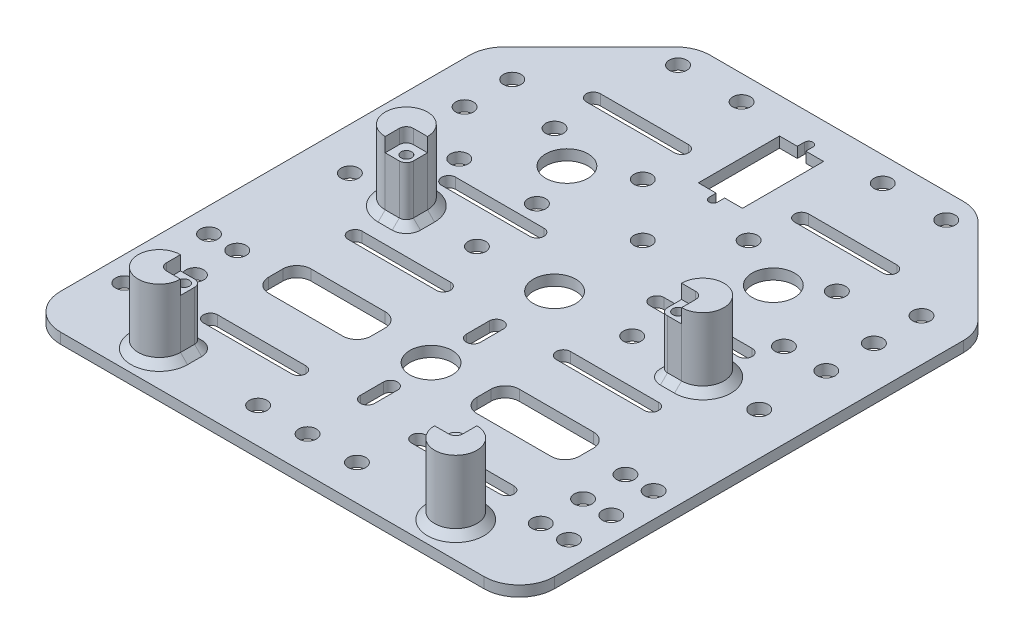
from build123d import *

# Parameters (mm, degrees)
SKETCH_1_W           = 140
SKETCH_1_H           = 160
EXTRUDE_1_DEPTH      = 4
SKETCH_2_R           = 2.5
SKETCH_2_R_2         = 6
CUT_EXTRUDE_1_DEPTH  = 213.64054176
EXTRUDE_3_DEPTH      = 20
CUT_EXTRUDE_START    = 20
SKETCH_4_4_W         = 84
SKETCH_4_4_H         = 70
CUT_EXTRUDE_2_DEPTH  = 4
FILLET_2_R           = 2
SKETCH_8_R           = 1.5
CUT_EXTRUDE_4_DEPTH  = 4
FILLET_3_R           = 2
CHAMFER_5_SIZE       = 2
SKETCH_1_2_W         = 140
SKETCH_1_2_H         = 160
CUT_EXTRUDE_6_DEPTH  = 1
CHAMFER_6_SIZE       = 30
SKETCH_5_W           = 12.5
SKETCH_5_H           = 23
CUT_EXTRUDE_8_DEPTH  = 214.541565041
SKETCH_14_R          = 2.5
CUT_EXTRUDE_9_DEPTH  = 214.541565041
FILLET_4_R           = 4
FILLET_5_R           = 10
CUT_EXTRUDE_10_DEPTH = 214.541565041


with BuildPart() as part:
    # Sketch 1 → Extrude 1 (new body)
    with BuildSketch(Plane(origin=(0, 0, 0), x_dir=(1, 0, 0), z_dir=(0, 1, 0))):
        with Locations((70, 80)):
            Rectangle(SKETCH_1_W, SKETCH_1_H)
    extrude(amount=EXTRUDE_1_DEPTH)

    # Sketch 2 → Cut-Extrude 1 (cut, through all)
    with BuildSketch(Plane(origin=(0, 4, 0), x_dir=(1, 0, 0), z_dir=(0, 1, 0))):
        with Locations(Location((55, 120, 0), (0, 0, 270))):
            Circle(SKETCH_2_R)
        with Locations(Location((85, 120, 0), (0, 0, 270))):
            Circle(SKETCH_2_R)
        with Locations(Location((12, 112.5, 0), (0, 0, 270))):
            Circle(SKETCH_2_R)
        with Locations(Location((128, 112.5, 0), (0, 0, 270))):
            Circle(SKETCH_2_R)
        with Locations(Location((12, 80, 0), (0, 0, 270))):
            Circle(SKETCH_2_R)
        with Locations(Location((128, 80, 0), (0, 0, 270))):
            Circle(SKETCH_2_R)
        with Locations(Location((7, 45.08040742, 0), (0, 0, 270))):
            Circle(SKETCH_2_R)
        with Locations(Location((15, 45.08040742, 0), (0, 0, 270))):
            Circle(SKETCH_2_R)
        with Locations(Location((15, 33.08040742, 0), (0, 0, 270))):
            Circle(SKETCH_2_R)
        with Locations(Location((15, 21.08040742, 0), (0, 0, 270))):
            Circle(SKETCH_2_R)
        with Locations(Location((7, 33.08040742, 0), (0, 0, 270))):
            Circle(SKETCH_2_R)
        with Locations(Location((7, 21.08040742, 0), (0, 0, 270))):
            Circle(SKETCH_2_R)
        with Locations(Location((133, 21.08040742, 0), (0, 0, 90))):
            Circle(SKETCH_2_R)
        with Locations(Location((133, 33.08040742, 0), (0, 0, 90))):
            Circle(SKETCH_2_R)
        with Locations(Location((125, 21.08040742, 0), (0, 0, 90))):
            Circle(SKETCH_2_R)
        with Locations(Location((125, 33.08040742, 0), (0, 0, 90))):
            Circle(SKETCH_2_R)
        with Locations(Location((125, 45.08040742, 0), (0, 0, 90))):
            Circle(SKETCH_2_R)
        with Locations(Location((133, 45.08040742, 0), (0, 0, 90))):
            Circle(SKETCH_2_R)
        with Locations(Location((70, 45, 0), (0, 0, 270))):
            Circle(SKETCH_2_R_2)
        with Locations(Location((70, 80, 0), (0, 0, 270))):
            Circle(SKETCH_2_R_2)
        with Locations(Location((12, 126, 0), (0, 0, 270))):
            Circle(SKETCH_2_R)
        with Locations(Location((128, 126, 0), (0, 0, 270))):
            Circle(SKETCH_2_R)
        with Locations(Location((70, 105, 0), (0, 0, 270))):
            Circle(SKETCH_2_R)
        with Locations(Location((12, 99, 0), (0, 0, 270))):
            Circle(SKETCH_2_R)
        with Locations(Location((128, 99, 0), (0, 0, 270))):
            Circle(SKETCH_2_R)
        with Locations(Location((41, 112.5, 0), (0, 0, 270))):
            Circle(SKETCH_2_R_2)
        with Locations(Location((99.5, 112.5, 0), (0, 0, 270))):
            Circle(SKETCH_2_R_2)
        with Locations(Location((30, 120, 0), (0, 0, 270))):
            Circle(SKETCH_2_R)
        with Locations(Location((110, 120, 0), (0, 0, 270))):
            Circle(SKETCH_2_R)
        with Locations(Location((70, 10, 0), (0, 0, 270))):
            Circle(SKETCH_2_R)
        with Locations(Location((56, 10, 0), (0, 0, 270))):
            Circle(SKETCH_2_R)
        with Locations(Location((84, 10, 0), (0, 0, 270))):
            Circle(SKETCH_2_R)
        with Locations(Location((48, 80, 0), (0, 0, 270))):
            Circle(SKETCH_2_R)
        with Locations(Location((30, 80, 0), (0, 0, 270))):
            Circle(SKETCH_2_R)
        with Locations(Location((92, 80, 0), (0, 0, 270))):
            Circle(SKETCH_2_R)
        with Locations(Location((110, 80, 0), (0, 0, 270))):
            Circle(SKETCH_2_R)
        with BuildLine():
            Line((28, 26.5), (53, 26.5))
            ThreePointArc((53, 26.5), (55, 24.5), (53, 22.5))
            Line((53, 22.5), (28, 22.5))
            ThreePointArc((28, 22.5), (26, 24.5), (28, 26.5))
        make_face()
        with BuildLine():
            Line((28, 94), (53, 94))
            ThreePointArc((53, 94), (55, 92), (53, 90))
            Line((53, 90), (28, 90))
            ThreePointArc((28, 90), (26, 92), (28, 94))
        make_face()
        with BuildLine():
            Line((87, 94), (112, 94))
            ThreePointArc((112, 94), (114, 92), (112, 90))
            Line((112, 90), (87, 90))
            ThreePointArc((87, 90), (85, 92), (87, 94))
        make_face()
        with BuildLine():
            Line((28, 135), (53, 135))
            ThreePointArc((53, 135), (55, 133), (53, 131))
            Line((53, 131), (28, 131))
            ThreePointArc((28, 131), (26, 133), (28, 135))
        make_face()
        with BuildLine():
            Line((87, 26.5), (112, 26.5))
            ThreePointArc((112, 26.5), (114, 24.5), (112, 22.5))
            Line((112, 22.5), (87, 22.5))
            ThreePointArc((87, 22.5), (85, 24.5), (87, 26.5))
        make_face()
        with BuildLine():
            Line((87, 135), (112, 135))
            ThreePointArc((112, 135), (114, 133), (112, 131))
            Line((112, 131), (87, 131))
            ThreePointArc((87, 131), (85, 133), (87, 135))
        make_face()
        Polygon((40.5, 51), (26, 51), (26, 39), (55, 39), (55, 51), align=None)
        with BuildLine():
            Line((28, 67.5), (53, 67.5))
            ThreePointArc((53, 67.5), (55, 65.5), (53, 63.5))
            Line((53, 63.5), (28, 63.5))
            ThreePointArc((28, 63.5), (26, 65.5), (28, 67.5))
        make_face()
        with BuildLine():
            Line((87, 67.5), (112, 67.5))
            ThreePointArc((112, 67.5), (114, 65.5), (112, 63.5))
            Line((112, 63.5), (87, 63.5))
            ThreePointArc((87, 63.5), (85, 65.5), (87, 67.5))
        make_face()
        Polygon((99.5, 51), (85, 51), (85, 39), (114, 39), (114, 51), align=None)
        with BuildLine():
            Line((72, 63.5), (72, 57))
            ThreePointArc((72, 57), (70, 55), (68, 57))
            Line((68, 57), (68, 63.5))
            ThreePointArc((68, 63.5), (70, 65.5), (72, 63.5))
        make_face()
        with BuildLine():
            Line((72, 33.5), (72, 27))
            ThreePointArc((72, 27), (70, 25), (68, 27))
            Line((68, 27), (68, 33.5))
            ThreePointArc((68, 33.5), (70, 35.5), (72, 33.5))
        make_face()
    extrude(amount=-CUT_EXTRUDE_1_DEPTH, mode=Mode.SUBTRACT)

    # Sketch 4 → Extrude 3 (add)
    with BuildSketch(Plane(origin=(0, 4, 0), x_dir=(1, 0, 0), z_dir=(0, 1, 0))):
        with BuildLine():
            Line((28, 74), (28, 80))
            Line((28, 80), (34, 80))
            ThreePointArc((34, 80), (23.757359313, 84.242640687), (28, 74))
        make_face()
        with BuildLine():
            Line((34, 80), (28, 80))
            Line((28, 80), (28, 74))
            ThreePointArc((28, 74), (32.242640687, 75.757359313), (34, 80))
        make_face()
        with BuildLine():
            ThreePointArc((118, 80), (112, 86), (106, 80))
            Line((106, 80), (112, 80))
            Line((112, 80), (112, 74))
            ThreePointArc((112, 74), (116.242640687, 75.757359313), (118, 80))
        make_face()
        with BuildLine():
            Line((112, 80), (106, 80))
            ThreePointArc((106, 80), (107.757359313, 75.757359313), (112, 74))
            Line((112, 74), (112, 80))
        make_face()
        with BuildLine():
            ThreePointArc((118, 10), (116.242640687, 14.242640687), (112, 16))
            Line((112, 16), (112, 10))
            Line((112, 10), (106, 10))
            ThreePointArc((106, 10), (112, 4), (118, 10))
        make_face()
        with BuildLine():
            Line((112, 10), (112, 16))
            ThreePointArc((112, 16), (107.757359313, 14.242640687), (106, 10))
            Line((106, 10), (112, 10))
        make_face()
        with BuildLine():
            ThreePointArc((34, 10), (32.242640687, 14.242640687), (28, 16))
            Line((28, 16), (28, 10))
            Line((28, 10), (34, 10))
        make_face()
        with BuildLine():
            Line((28, 10), (28, 16))
            ThreePointArc((28, 16), (23.757359313, 5.757359313), (34, 10))
            Line((34, 10), (28, 10))
        make_face()
        with BuildLine():
            Line((34, 74), (34, 80))
            ThreePointArc((34, 80), (32.242640687, 75.757359313), (28, 74))
            Line((28, 74), (34, 74))
        make_face()
        with BuildLine():
            ThreePointArc((112, 74), (107.757359313, 75.757359313), (106, 80))
            Line((106, 80), (106, 74))
            Line((106, 74), (112, 74))
        make_face()
        with BuildLine():
            ThreePointArc((106, 10), (107.757359313, 14.242640687), (112, 16))
            Line((112, 16), (106, 16))
            Line((106, 16), (106, 10))
        make_face()
        with BuildLine():
            Line((34, 16), (28, 16))
            ThreePointArc((28, 16), (32.242640687, 14.242640687), (34, 10))
            Line((34, 10), (34, 16))
        make_face()
    extrude(amount=EXTRUDE_3_DEPTH)

    # Sketch 4_4 → Cut-Extrude 2 (cut)
    with BuildSketch(Plane(origin=(0, 4, 0), x_dir=(1, 0, 0), z_dir=(0, 1, 0)).offset(CUT_EXTRUDE_START)):
        with Locations((70, 45)):
            Rectangle(SKETCH_4_4_W, SKETCH_4_4_H)
    extrude(amount=-CUT_EXTRUDE_2_DEPTH, mode=Mode.SUBTRACT)

    # Fillet 2
    fillet_2_edges = [part.edges().sort_by_distance(p)[0] for p in [
        (112, 22, -80),
        (112, 22, -10),
        (28, 22, -10),
        (28, 22, -80),
    ]]
    fillet(fillet_2_edges, radius=FILLET_2_R)

    # Sketch 8 → Cut-Extrude 4 (cut)
    with BuildSketch(Plane(origin=(0, 20, 0), x_dir=(1, 0, 0), z_dir=(0, 1, 0))):
        with Locations(Location((31.5, 13.5, 0), (0, 0, 270))):
            Circle(SKETCH_8_R)
        with Locations(Location((108.5, 76.5, 0), (0, 0, 270))):
            Circle(SKETCH_8_R)
        with Locations(Location((31.5, 76.5, 0), (0, 0, 270))):
            Circle(SKETCH_8_R)
        with Locations(Location((108.5, 13.5, 0), (0, 0, 270))):
            Circle(SKETCH_8_R)
    extrude(amount=-CUT_EXTRUDE_4_DEPTH, mode=Mode.SUBTRACT)

    # Fillet 3
    fillet_3_edges = [part.edges().sort_by_distance(p)[0] for p in [
        (34, 12, -16),
        (106, 12, -16),
        (106, 12, -74),
        (34, 12, -74),
    ]]
    fillet(fillet_3_edges, radius=FILLET_3_R)

    # Chamfer 5
    chamfer_5_edges = [part.edges().sort_by_distance(p)[0] for p in [
        (23.757359313, 4, -84.242640687),
        (30, 4, -74),
        (34, 4, -78),
        (116.242640687, 4, -84.242640687),
        (106, 4, -78),
        (116.242640687, 4, -5.757359313),
        (110, 4, -16),
        (23.757359313, 4, -5.757359313),
        (30, 4, -16),
        (106, 4, -12),
        (34, 4, -12),
        (110, 4, -74),
        (106.585786438, 4, -15.414213562),
        (33.414213562, 4, -15.414213562),
        (106.585786438, 4, -74.585786438),
        (33.414213562, 4, -74.585786438),
    ]]
    chamfer(chamfer_5_edges, length=CHAMFER_5_SIZE)

    # Sketch 1_2 → Cut-Extrude 6 (cut)
    with BuildSketch(Plane(origin=(0, 0, 0), x_dir=(1, 0, 0), z_dir=(0, 1, 0))):
        with Locations((70, 80)):
            Rectangle(SKETCH_1_2_W, SKETCH_1_2_H)
    extrude(amount=CUT_EXTRUDE_6_DEPTH, mode=Mode.SUBTRACT)

    # Chamfer 6
    chamfer_6_edges = [part.edges().sort_by_distance(p)[0] for p in [
        (0, 2.5, -160),
        (140, 2.5, -160),
    ]]
    chamfer(chamfer_6_edges, length=CHAMFER_6_SIZE)

    # Sketch 5 → Cut-Extrude 8 (cut, through all)
    with BuildSketch(Plane(origin=(0, 4, 0), x_dir=(1, 0, 0), z_dir=(0, 1, 0))):
        with Locations((70, 138.5)):
            Rectangle(SKETCH_5_W, SKETCH_5_H)
    extrude(amount=-CUT_EXTRUDE_8_DEPTH, mode=Mode.SUBTRACT)

    # Sketch 14 → Cut-Extrude 9 (cut, through all)
    with BuildSketch(Plane(origin=(0, 4, 0), x_dir=(1, 0, 0), z_dir=(0, 1, 0))):
        with Locations(Location((32, 153, 0), (0, 0, 270))):
            Circle(SKETCH_14_R)
        with Locations(Location((108, 153, 0), (0, 0, 270))):
            Circle(SKETCH_14_R)
        with Locations(Location((50, 153, 0), (0, 0, 270))):
            Circle(SKETCH_14_R)
        with Locations(Location((90, 153, 0), (0, 0, 270))):
            Circle(SKETCH_14_R)
        with Locations(Location((116, 99, 0), (0, 0, 270))):
            Circle(SKETCH_14_R)
        with Locations(Location((94, 99, 0), (0, 0, 270))):
            Circle(SKETCH_14_R)
        with Locations(Location((46, 99, 0), (0, 0, 270))):
            Circle(SKETCH_14_R)
        with Locations(Location((24, 99, 0), (0, 0, 270))):
            Circle(SKETCH_14_R)
    extrude(amount=-CUT_EXTRUDE_9_DEPTH, mode=Mode.SUBTRACT)

    # Fillet 4
    fillet_4_edges = [part.edges().sort_by_distance(p)[0] for p in [
        (85, 2.5, -51),
        (114, 2.5, -51),
        (85, 2.5, -39),
        (114, 2.5, -39),
        (26, 2.5, -51),
        (55, 2.5, -51),
        (26, 2.5, -39),
        (55, 2.5, -39),
    ]]
    fillet(fillet_4_edges, radius=FILLET_4_R)

    # Fillet 5
    fillet_5_edges = [part.edges().sort_by_distance(p)[0] for p in [
        (30, 2.5, -160),
        (110, 2.5, -160),
        (140, 2.5, -130),
        (0, 2.5, -130),
        (140, 2.5, 0),
        (0, 2.5, 0),
    ]]
    fillet(fillet_5_edges, radius=FILLET_5_R)

    # Sketch 11 → Cut-Extrude 10 (cut, through all)
    with BuildSketch(Plane(origin=(0, 4, 0), x_dir=(1, 0, 0), z_dir=(0, 1, 0))):
        with BuildLine():
            Line((71.2, 150), (71.2, 152))
            ThreePointArc((71.2, 152), (70, 153.2), (68.8, 152))
            Line((68.8, 152), (68.8, 150))
            Line((68.8, 150), (71.2, 150))
        make_face()
        with BuildLine():
            Line((71.2, 127), (68.8, 127))
            Line((68.8, 127), (68.8, 125))
            ThreePointArc((68.8, 125), (70, 123.8), (71.2, 125))
            Line((71.2, 125), (71.2, 127))
        make_face()
    extrude(amount=-CUT_EXTRUDE_10_DEPTH, mode=Mode.SUBTRACT)


solid = part.part
